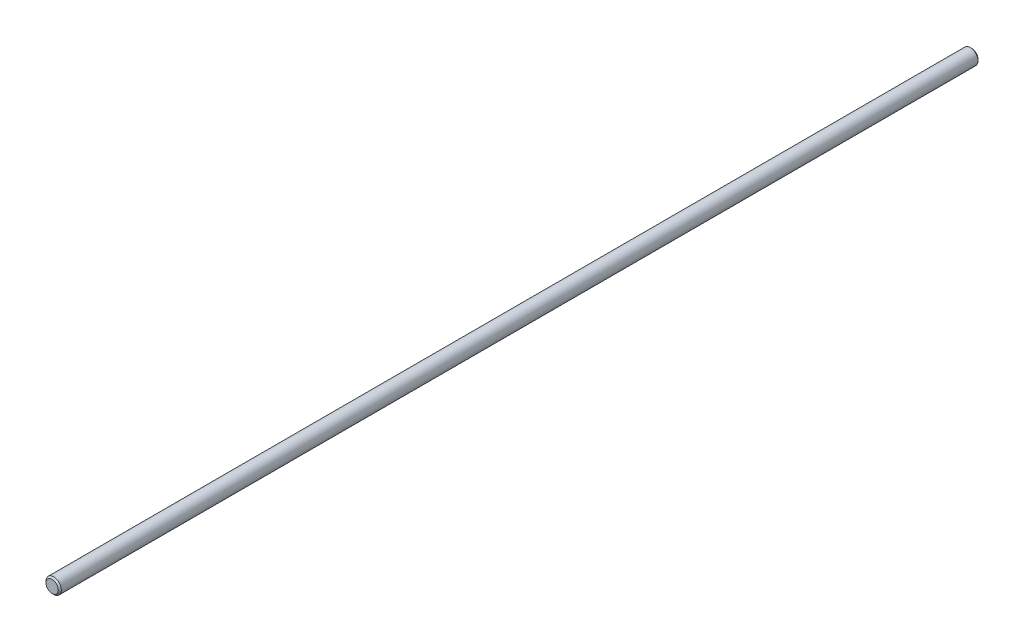
from build123d import *

# Parameters (mm, degrees)
SKETCH1_R           = 2.5
BOSS_EXTRUDE1_DEPTH = 300
CHAMFER1_SIZE       = 0.5


with BuildPart() as part:
    # Sketch1 → Boss-Extrude1 (new body)
    with BuildSketch(Plane.XY):
        Circle(SKETCH1_R)
    extrude(amount=-BOSS_EXTRUDE1_DEPTH)

    # Chamfer1
    chamfer1_edges = [part.edges().sort_by_distance(p)[0] for p in [
        (-2.5, 0, 0),
        (-2.5, 0, -300),
    ]]
    chamfer(chamfer1_edges, length=CHAMFER1_SIZE)


solid = part.part
